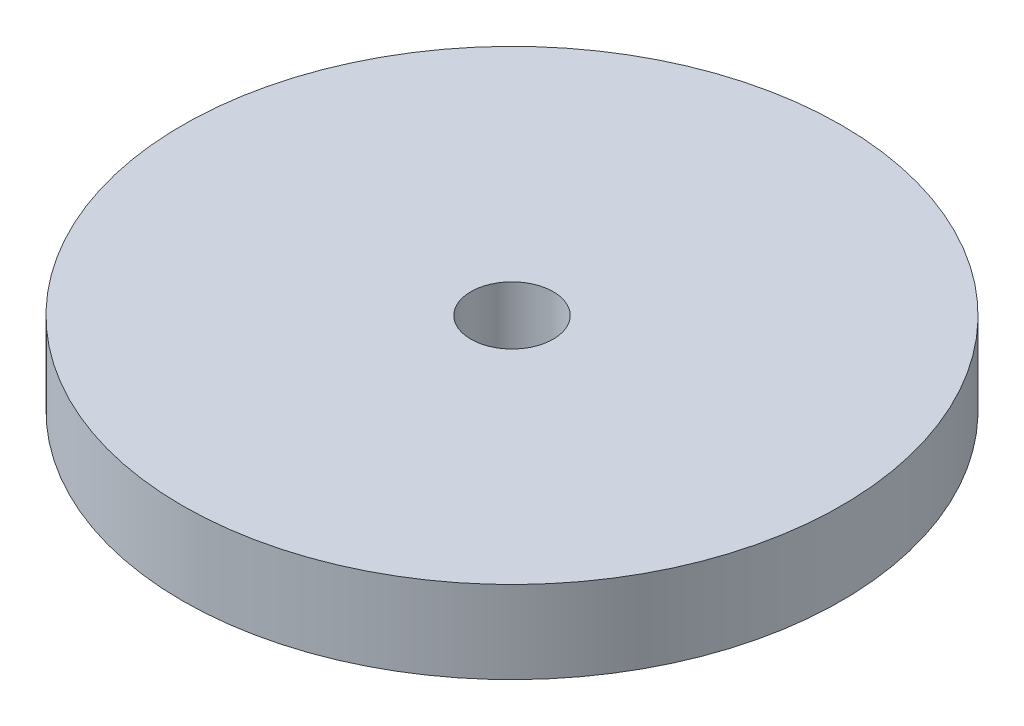
from build123d import *

# Parameters (mm, degrees)
SKETCH1_R           = 25.4
SKETCH1_R_2         = 3.175
BOSS_EXTRUDE1_DEPTH = 6.35


with BuildPart() as part:
    # Sketch1 → Boss-Extrude1 (new body)
    with BuildSketch(Plane(origin=(0, 0, 0), x_dir=(1, 0, 0), z_dir=(0, 1, 0))):
        Circle(SKETCH1_R)
        Circle(SKETCH1_R_2, mode=Mode.SUBTRACT)
    extrude(amount=BOSS_EXTRUDE1_DEPTH)


solid = part.part
